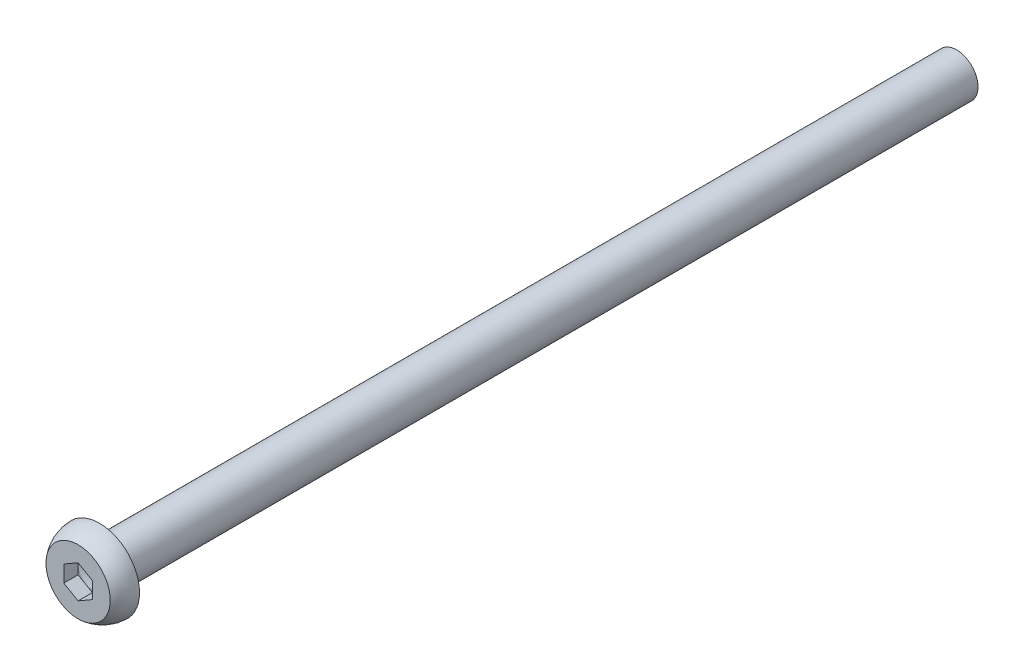
from build123d import *

# Parameters (mm, degrees)
CUT_EXTRUDE_2_DEPTH = 1
SKETCH_3_R          = 1.5
EXTRUDE_1_DEPTH     = 60


with BuildPart() as part:
    # 草图1 → 旋转1 (revolve)
    with BuildSketch(Plane(origin=(0, 0, 0), x_dir=(0, 0, -1), z_dir=(1, 0, 0))):
        with BuildLine():
            Line((0, 2.250343623), (0, 1))
            Line((0, 1), (0, 0))
            Line((0, 0), (1, 0))
            Line((1, 0), (1, 1))
            Line((1, 1), (1.248177586, 0))
            Line((1.248177586, 0), (1.5, 0))
            Line((1.5, 0), (1.5, 1.5))
            Line((1.5, 1.5), (1.5, 2.8))
            ThreePointArc((1.5, 2.8), (0.701231865, 2.658258964), (0, 2.250343623))
        make_face()
    revolve(axis=Axis((0, 0, 0), (0, 0, -1)))

    # 草图2 → 切除-拉伸2 (cut)
    with BuildSketch(Plane.XY):
        Polygon((0, 1.154700538), (-1, 0.577350269), (-1, -0.577350269), (0, -1.154700538), (1, -0.577350269), (1, 0.577350269), align=None)
    extrude(amount=-CUT_EXTRUDE_2_DEPTH, mode=Mode.SUBTRACT)

    # 草图3 → 凸台-拉伸1 (add)
    with BuildSketch(Plane(origin=(0, 0, -1.5), x_dir=(-1, 0, 0), z_dir=(0, 0, -1))):
        Circle(SKETCH_3_R)
    extrude(amount=EXTRUDE_1_DEPTH)


solid = part.part
